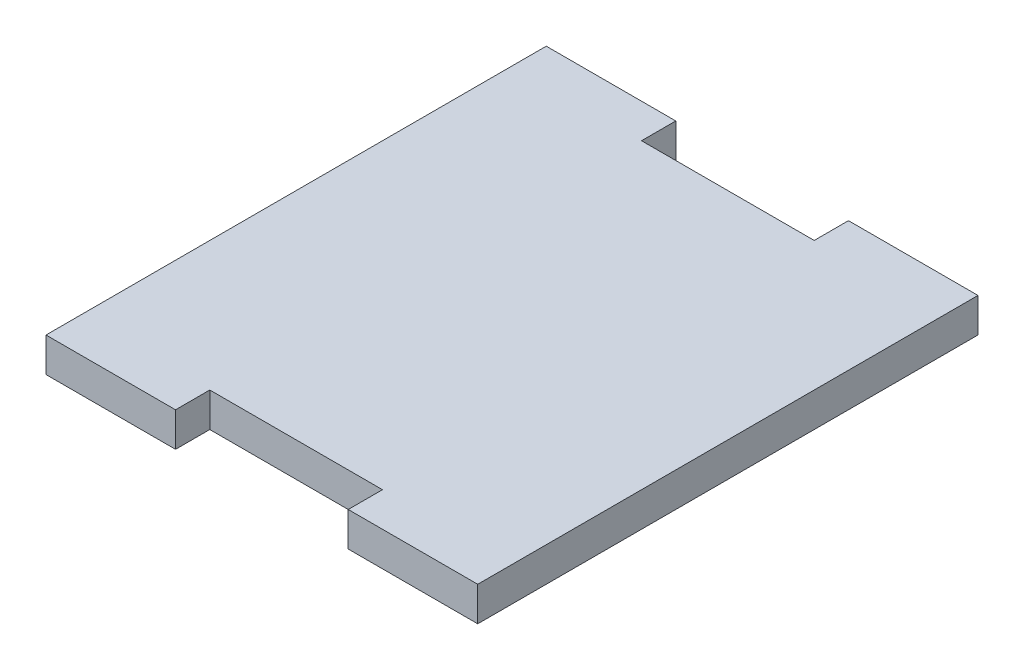
from build123d import *

# Parameters (mm, degrees)
BOSS_EXTRUDE1_DEPTH = 3.175


with BuildPart() as part:
    # Sketch1 → Boss-Extrude1 (new body)
    with BuildSketch(Plane(origin=(0, 0, 0), x_dir=(1, 0, 0), z_dir=(0, 1, 0))):
        Polygon((-25.530201342, -14.852852349), (-13.530201342, -14.852852349), (-13.530201342, -11.677852349), (2.469798658, -11.677852349), (2.469798658, -14.852852349), (14.469798658, -14.852852349), (14.469798658, 31.497147651), (2.469798658, 31.497147651), (2.469798658, 28.322147651), (-13.530201342, 28.322147651), (-13.530201342, 31.497147651), (-25.530201342, 31.497147651), align=None)
    extrude(amount=BOSS_EXTRUDE1_DEPTH)


solid = part.part
